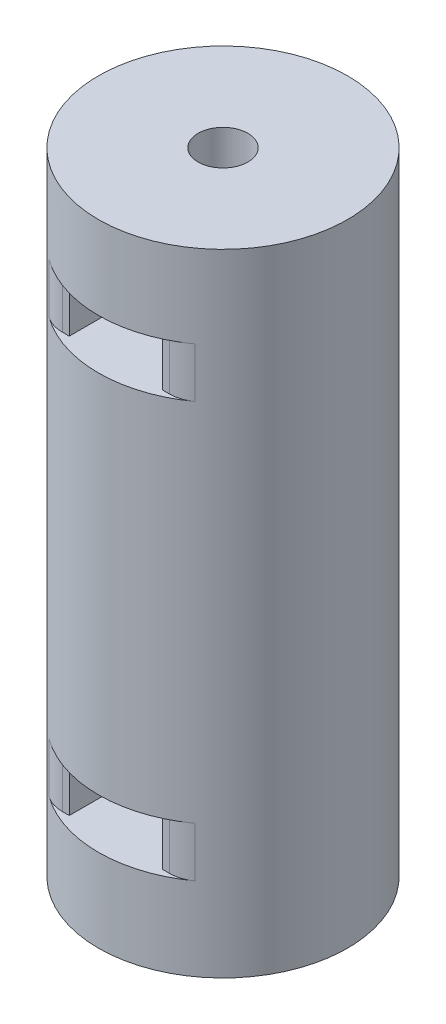
from build123d import *

# Parameters (mm, degrees)
SKETCH1_R           = 7.5
SKETCH1_R_2         = 1.5
BOSS_EXTRUDE1_DEPTH = 38
SKETCH2_W           = 5.6
SKETCH2_H           = 17.764538462
CUT_EXTRUDE1_DEPTH  = 3
SKETCH3_W           = 5.6
SKETCH3_H           = 17.764538462
CUT_EXTRUDE2_DEPTH  = 3
SKETCH4_W           = 28.563856461
SKETCH4_H           = 7.504556993
SKETCH4_W_2         = 23.531731035
SKETCH4_H_2         = 6.282884924
CUT_EXTRUDE3_DEPTH  = 3
SKETCH5_W           = 28.563856461
SKETCH5_H           = 7.504556993
SKETCH5_W_2         = 23.531731035
SKETCH5_H_2         = 6.282884924
CUT_EXTRUDE4_DEPTH  = 3
FILLET1_R           = 2


with BuildPart() as part:
    # Sketch1 → Boss-Extrude1 (new body)
    with BuildSketch(Plane(origin=(0, 0, 0), x_dir=(1, 0, 0), z_dir=(0, 1, 0))):
        Circle(SKETCH1_R)
        Circle(SKETCH1_R_2, mode=Mode.SUBTRACT)
    extrude(amount=BOSS_EXTRUDE1_DEPTH)

    # Sketch2 → Cut-Extrude1 (cut)
    with BuildSketch(Plane(origin=(0, 33, 0), x_dir=(1, 0, 0), z_dir=(0, 1, 0))):
        Rectangle(SKETCH2_W, SKETCH2_H)
    extrude(amount=-CUT_EXTRUDE1_DEPTH, mode=Mode.SUBTRACT)

    # Sketch3 → Cut-Extrude2 (cut)
    with BuildSketch(Plane(origin=(0, 5, 0), x_dir=(-1, 0, 0), z_dir=(0, -1, 0))):
        Rectangle(SKETCH3_W, SKETCH3_H)
    extrude(amount=-CUT_EXTRUDE2_DEPTH, mode=Mode.SUBTRACT)

    # Sketch4 → Cut-Extrude3 (cut)
    with BuildSketch(Plane(origin=(0, 33, 0), x_dir=(1, 0, 0), z_dir=(0, 1, 0))):
        with Locations((0.852860298, 10.210008012)):
            Rectangle(SKETCH4_W, SKETCH4_H)
        with Locations((0.954666304, -9.599171977)):
            Rectangle(SKETCH4_W_2, SKETCH4_H_2)
    extrude(amount=-CUT_EXTRUDE3_DEPTH, mode=Mode.SUBTRACT)

    # Sketch5 → Cut-Extrude4 (cut)
    with BuildSketch(Plane(origin=(0, 5, 0), x_dir=(-1, 0, 0), z_dir=(0, -1, 0))):
        with Locations((-0.852860298, 10.210008012)):
            Rectangle(SKETCH5_W, SKETCH5_H)
        with Locations((-0.954666304, -9.599171977)):
            Rectangle(SKETCH5_W_2, SKETCH5_H_2)
    extrude(amount=-CUT_EXTRUDE4_DEPTH, mode=Mode.SUBTRACT)

    # Fillet1
    fillet1_edges = [part.edges().sort_by_distance(p)[0] for p in [
        (-3.814148596, 6.5, -6.457729515),
        (3.814148596, 6.5, -6.457729515),
        (3.814148596, 6.5, 6.457729515),
        (-3.814148596, 6.5, 6.457729515),
        (-3.814148596, 31.5, -6.457729515),
        (3.814148596, 31.5, -6.457729515),
        (3.814148596, 31.5, 6.457729515),
        (-3.814148596, 31.5, 6.457729515),
    ]]
    fillet(fillet1_edges, radius=FILLET1_R)


solid = part.part
